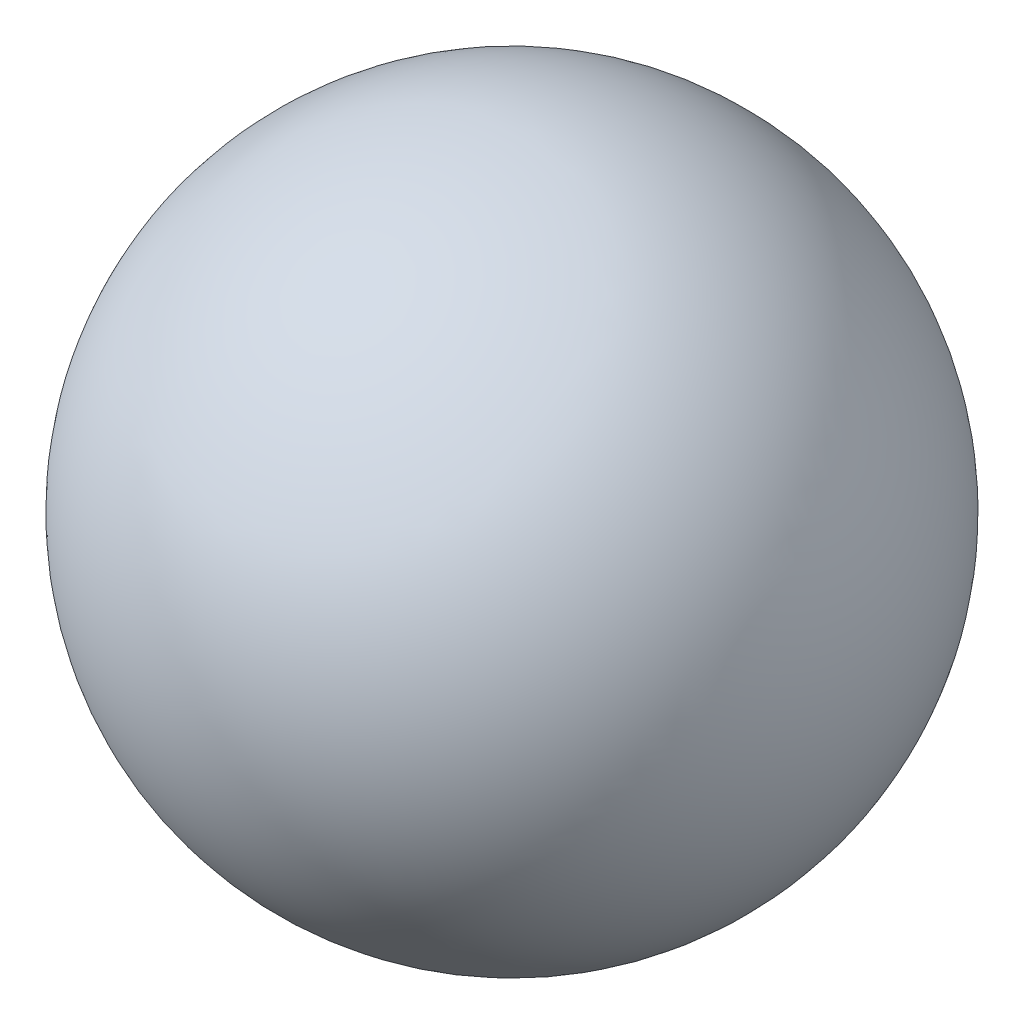
from build123d import *


with BuildPart() as part:
    # Sketch1 → Revolve3 (revolve)
    with BuildSketch(Plane.XY):
        with BuildLine():
            Line((-1.9845, 0), (1.9845, 0))
            ThreePointArc((1.9845, 0), (0, 1.9845), (-1.9845, 0))
        make_face()
    revolve(axis=Axis((-5.474681738, 0, 0), (1, 0, 0)))


solid = part.part
